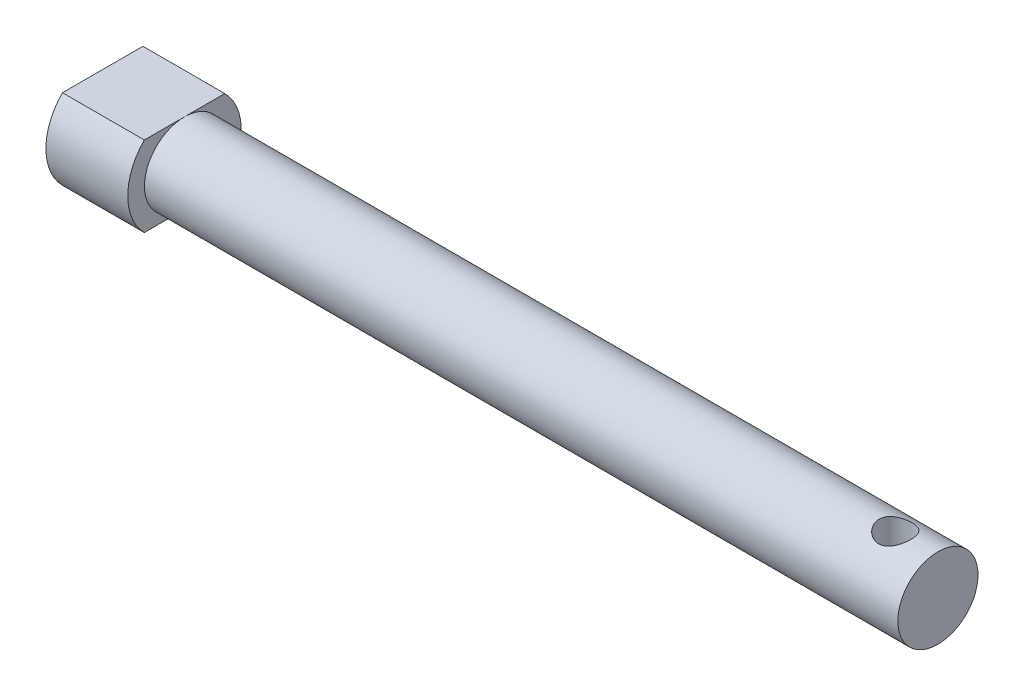
from build123d import *

# Parameters (mm, degrees)
SKETCH2_R               = 2.4
BOSS_EXTRUDE1_DEPTH     = 25
BOSS_EXTRUDE4_DEPTH     = 4.9
SKETCH5_R               = 1
CUT_EXTRUDE2_DEPTH      = 1
CUT_EXTRUDE2_DEPTH_BACK = 5.8


with BuildPart() as part:
    # Sketch2 → Boss-Extrude1 (new body, symmetric)
    with BuildSketch(Plane(origin=(0, 0, 0), x_dir=(0, 0, -1), z_dir=(1, 0, 0))):
        Circle(SKETCH2_R)
    extrude(amount=BOSS_EXTRUDE1_DEPTH, both=True)

    # Sketch3 → Boss-Extrude4 (add)
    with BuildSketch(Plane.ZY.offset(25)):
        with BuildLine():
            Line((0, 2.4), (-2.408318916, 2.4))
            ThreePointArc((-2.408318916, 2.4), (-3.4, 0), (-2.408318916, -2.4))
            Line((-2.408318916, -2.4), (0, -2.4))
            ThreePointArc((0, -2.4), (-2.4, 0), (0, 2.4))
        make_face()
        with BuildLine():
            Line((2.408318916, 2.4), (0, 2.4))
            ThreePointArc((0, 2.4), (1.697056275, 1.697056275), (2.4, 0))
            ThreePointArc((2.4, 0), (1.697056275, -1.697056275), (0, -2.4))
            Line((0, -2.4), (2.408318916, -2.4))
            ThreePointArc((2.408318916, -2.4), (3.142314777, -1.298405885), (3.4, 0))
            ThreePointArc((3.4, 0), (3.142314777, 1.298405885), (2.408318916, 2.4))
        make_face()
    extrude(amount=-BOSS_EXTRUDE4_DEPTH)

    # Sketch5 → Cut-Extrude2 (cut, two sides)
    with BuildSketch(Plane(origin=(0, 2.4, 0), x_dir=(1, 0, 0), z_dir=(0, 1, 0))) as cut_extrude2_sk:
        with Locations((22.55, -0.1)):
            Circle(SKETCH5_R)
    extrude(amount=CUT_EXTRUDE2_DEPTH, mode=Mode.SUBTRACT)
    extrude(cut_extrude2_sk.sketch, amount=-CUT_EXTRUDE2_DEPTH_BACK, mode=Mode.SUBTRACT)


solid = part.part
